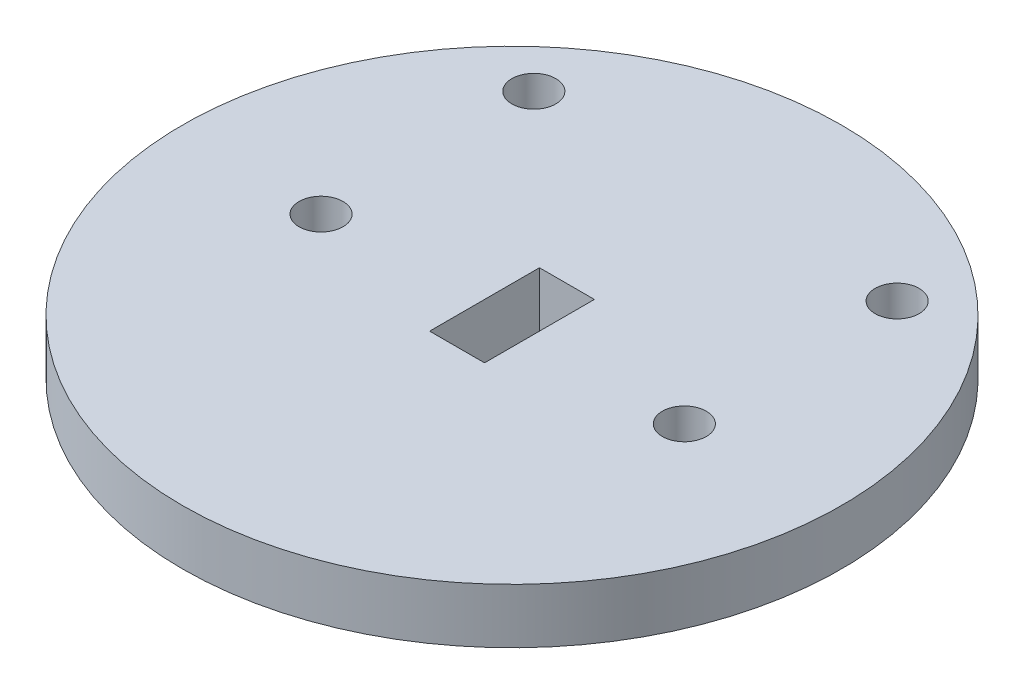
from build123d import *

# Parameters (mm, degrees)
SKETCH1_R           = 19.05
SKETCH1_W           = 3.175
SKETCH1_H           = 6.35
BOSS_EXTRUDE1_DEPTH = 3.175
SKETCH2_R           = 1.27
CUT_EXTRUDE1_DEPTH  = 4.175


with BuildPart() as part:
    # Sketch1 → Boss-Extrude1 (new body)
    with BuildSketch(Plane(origin=(0, 0, 0), x_dir=(1, 0, 0), z_dir=(0, 1, 0))):
        Circle(SKETCH1_R)
        Rectangle(SKETCH1_W, SKETCH1_H, mode=Mode.SUBTRACT)
    extrude(amount=BOSS_EXTRUDE1_DEPTH)

    # Sketch2 → Cut-Extrude1 (cut, through all)
    with BuildSketch(Plane(origin=(0, 3.175, 0), x_dir=(1, 0, 0), z_dir=(0, 1, 0))):
        with Locations((10.416417342, -0.454529354)):
            Circle(SKETCH2_R)
        with Locations((-10.583582658, -0.454529354)):
            Circle(SKETCH2_R)
        with Locations((-10.583582658, 11.845470646)):
            Circle(SKETCH2_R)
        with Locations((10.416417342, 11.845470646)):
            Circle(SKETCH2_R)
    extrude(amount=-CUT_EXTRUDE1_DEPTH, mode=Mode.SUBTRACT)


solid = part.part
